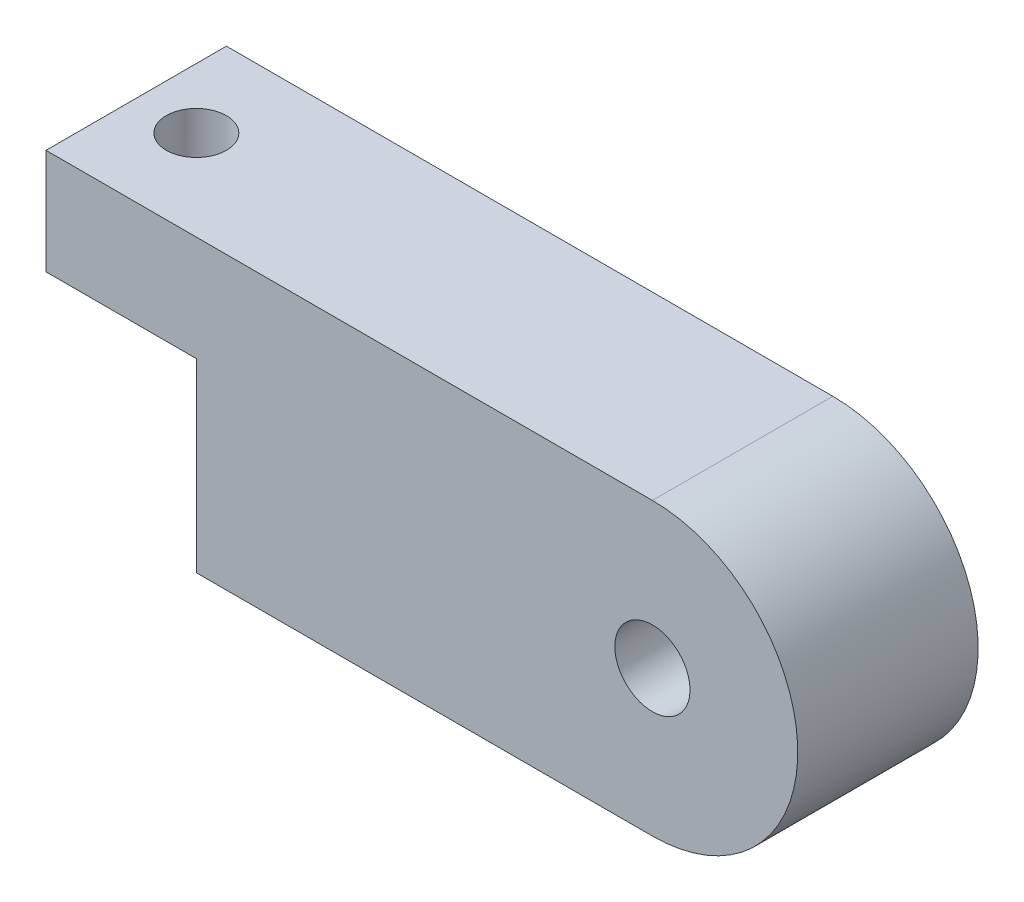
from build123d import *

# Parameters (mm, degrees)
SKETCH2_W           = 200
SKETCH2_H           = 96.666666667
BOSS_EXTRUDE2_DEPTH = 60
FILLET12_R          = 48.333333
SKETCH6_R           = 12.5
CUT_EXTRUDE3_DEPTH  = 61
SKETCH8_W           = 60
SKETCH8_H           = 35
BOSS_EXTRUDE3_DEPTH = 50
SKETCH10_R          = 10
CUT_EXTRUDE4_DEPTH  = 50


with BuildPart() as part:
    # Sketch2 → Boss-Extrude2 (new body)
    with BuildSketch(Plane.XY):
        with Locations((100, -48.333333334)):
            Rectangle(SKETCH2_W, SKETCH2_H)
    extrude(amount=-BOSS_EXTRUDE2_DEPTH)

    # Fillet12
    fillet12_edges = [part.edges().sort_by_distance(p)[0] for p in [
        (200, 0, -30),
        (200, -96.666666667, -30),
    ]]
    fillet(fillet12_edges, radius=FILLET12_R)

    # Sketch6 → Cut-Extrude3 (cut, through all)
    with BuildSketch(Plane(origin=(0, 0, -60), x_dir=(-1, 0, 0), z_dir=(0, 0, -1))):
        with Locations((-151.666666667, -48.333333333)):
            Circle(SKETCH6_R)
    extrude(amount=-CUT_EXTRUDE3_DEPTH, mode=Mode.SUBTRACT)

    # Sketch8 → Boss-Extrude3 (add)
    with BuildSketch(Plane.ZY):
        with Locations((-30, -17.5)):
            Rectangle(SKETCH8_W, SKETCH8_H)
    extrude(amount=BOSS_EXTRUDE3_DEPTH)

    # Sketch10 → Cut-Extrude4 (cut)
    with BuildSketch(Plane(origin=(0, 0, 0), x_dir=(1, 0, 0), z_dir=(0, 1, 0))):
        with Locations((-30, 30)):
            Circle(SKETCH10_R)
    extrude(amount=-CUT_EXTRUDE4_DEPTH, mode=Mode.SUBTRACT)


solid = part.part
